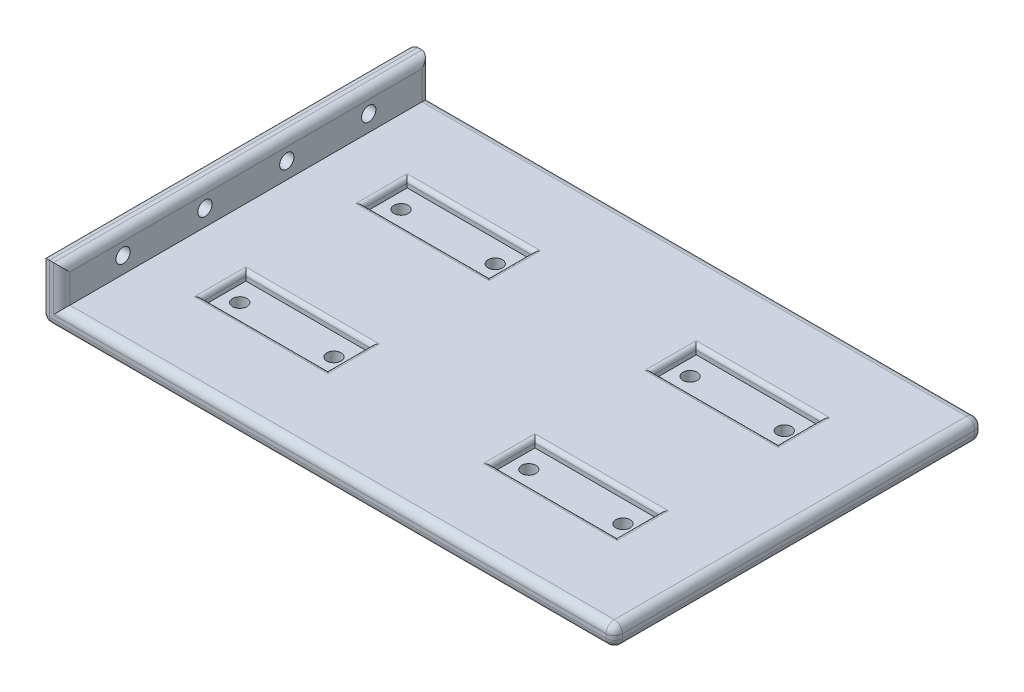
from build123d import *

# Parameters (mm, degrees)
SKETCH_1_W          = 140
SKETCH_1_H          = 90
EXTRUDE_1_DEPTH     = 5
SKETCH_2_W          = 5
SKETCH_2_H          = 90
EXTRUDE_2_DEPTH     = 9
SKETCH_3_R          = 1.75
CUT_EXTRUDE_1_DEPTH = 11
SKETCH_5_W          = 30.6
SKETCH_5_H          = 10.6
SKETCH_5_R          = 1.75
CUT_EXTRUDE_2_DEPTH = 2
SKETCH_5_3_R        = 1.75
CUT_EXTRUDE_3_DEPTH = 84.701851831
FILLET_1_R          = 2
FILLET_2_R          = 1


with BuildPart() as part:
    # ｽｹｯﾁ1 → ﾎﾞｽ - 押し出し1 (new body)
    with BuildSketch(Plane(origin=(0, 0, 0), x_dir=(1, 0, 0), z_dir=(0, 1, 0))):
        Rectangle(SKETCH_1_W, SKETCH_1_H)
    extrude(amount=EXTRUDE_1_DEPTH)

    # ｽｹｯﾁ2 → ﾎﾞｽ - 押し出し2 (add)
    with BuildSketch(Plane(origin=(0, 5, 0), x_dir=(1, 0, 0), z_dir=(0, 1, 0))):
        with Locations((-67.5, 0)):
            Rectangle(SKETCH_2_W, SKETCH_2_H)
    extrude(amount=EXTRUDE_2_DEPTH)

    # ｽｹｯﾁ3 → ｶｯﾄ - 押し出し1 (cut)
    with BuildSketch(Plane.ZY.offset(70)):
        with Locations((-30, 9)):
            Circle(SKETCH_3_R)
        with Locations((-10, 9)):
            Circle(SKETCH_3_R)
        with Locations((30, 9)):
            Circle(SKETCH_3_R)
        with Locations((10, 9)):
            Circle(SKETCH_3_R)
    extrude(amount=-CUT_EXTRUDE_1_DEPTH, mode=Mode.SUBTRACT)

    # ｽｹｯﾁ5 → ｶｯﾄ - 押し出し2 (cut)
    # profile 1 of 4: a face of its own
    with BuildSketch(Plane(origin=(0, 5, 0), x_dir=(1, 0, 0), z_dir=(0, 1, 0))):
        with Locations((-35.3, -19.7)):
            Rectangle(SKETCH_5_W, SKETCH_5_H)
        with Locations((-46.8, -19.7)):
            Circle(SKETCH_5_R, mode=Mode.SUBTRACT)
        with Locations((-23.8, -19.7)):
            Circle(SKETCH_5_R, mode=Mode.SUBTRACT)
    # profile 2 of 4: a face of its own
    with BuildSketch(Plane(origin=(0, 5, 0), x_dir=(1, 0, 0), z_dir=(0, 1, 0))):
        with Locations((-35.3, 19.7)):
            Rectangle(SKETCH_5_W, SKETCH_5_H)
        with Locations((-23.8, 19.7)):
            Circle(SKETCH_5_R, mode=Mode.SUBTRACT)
        with Locations((-46.8, 19.7)):
            Circle(SKETCH_5_R, mode=Mode.SUBTRACT)
    # profile 3 of 4: a face of its own
    with BuildSketch(Plane(origin=(0, 5, 0), x_dir=(1, 0, 0), z_dir=(0, 1, 0))):
        with Locations((35.3, 19.7)):
            Rectangle(SKETCH_5_W, SKETCH_5_H)
        with Locations((46.8, 19.7)):
            Circle(SKETCH_5_R, mode=Mode.SUBTRACT)
        with Locations((23.8, 19.7)):
            Circle(SKETCH_5_R, mode=Mode.SUBTRACT)
    # profile 4 of 4: a face of its own
    with BuildSketch(Plane(origin=(0, 5, 0), x_dir=(1, 0, 0), z_dir=(0, 1, 0))):
        with Locations((35.3, -19.7)):
            Rectangle(SKETCH_5_W, SKETCH_5_H)
        with Locations((23.8, -19.7)):
            Circle(SKETCH_5_R, mode=Mode.SUBTRACT)
        with Locations((46.8, -19.7)):
            Circle(SKETCH_5_R, mode=Mode.SUBTRACT)
    extrude(amount=-CUT_EXTRUDE_2_DEPTH, mode=Mode.SUBTRACT)

    # ｽｹｯﾁ5<3> → ｶｯﾄ - 押し出し3 (cut, through all)
    with BuildSketch(Plane(origin=(0, 5, 0), x_dir=(1, 0, 0), z_dir=(0, 1, 0))):
        with Locations((-46.8, -19.7)):
            Circle(SKETCH_5_3_R)
        with Locations((-23.8, -19.7)):
            Circle(SKETCH_5_3_R)
        with Locations((-23.8, 19.7)):
            Circle(SKETCH_5_3_R)
        with Locations((-46.8, 19.7)):
            Circle(SKETCH_5_3_R)
        with Locations((46.8, 19.7)):
            Circle(SKETCH_5_3_R)
        with Locations((23.8, 19.7)):
            Circle(SKETCH_5_3_R)
        with Locations((23.8, -19.7)):
            Circle(SKETCH_5_3_R)
        with Locations((46.8, -19.7)):
            Circle(SKETCH_5_3_R)
    extrude(amount=-CUT_EXTRUDE_3_DEPTH, mode=Mode.SUBTRACT)

    # ﾌｨﾚｯﾄ1
    fillet_1_edges = [part.edges().sort_by_distance(p)[0] for p in [
        (70, 0, 0),
        (70, 5, 0),
        (-65, 14, 0),
        (-70, 14, 0),
        (-70, 0, 0),
        (0, 0, -45),
        (2.5, 5, -45),
        (0, 0, 45),
        (2.5, 5, 45),
        (-65, 9.5, 45),
        (-65, 9.5, -45),
        (-70, 7, 45),
        (-70, 7, -45),
        (70, 2.5, 45),
        (70, 2.5, -45),
    ]]
    fillet(fillet_1_edges, radius=FILLET_1_R)

    # ﾌｨﾚｯﾄ2
    fillet_2_edges = [part.edges().sort_by_distance(p)[0] for p in [
        (20, 5, -19.7),
        (35.3, 5, -25),
        (35.3, 5, -14.4),
        (50.6, 5, -19.7),
        (50.6, 5, 19.7),
        (35.3, 5, 25),
        (20, 5, 19.7),
        (35.3, 5, 14.4),
        (-50.6, 5, -19.7),
        (-35.3, 5, -25),
        (-35.3, 5, -14.4),
        (-20, 5, -19.7),
        (-50.6, 5, 19.7),
        (-35.3, 5, 14.4),
        (-20, 5, 19.7),
        (-35.3, 5, 25),
    ]]
    fillet(fillet_2_edges, radius=FILLET_2_R)


solid = part.part
